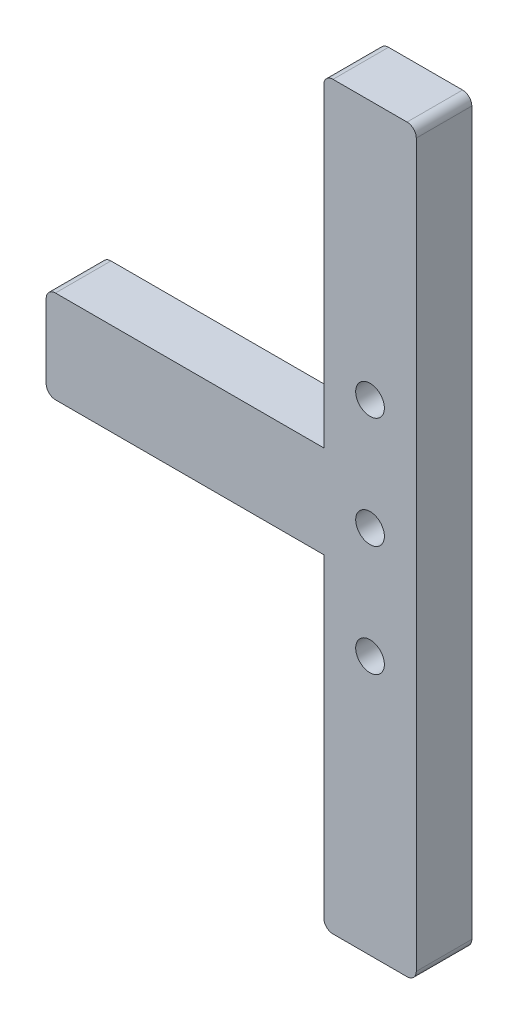
from build123d import *

# Parameters (mm, degrees)
SKETCH_1_W      = 10
SKETCH_1_H      = 80
SKETCH_1_R      = 1.55
SKETCH_1_W_2    = 30
SKETCH_1_H_2    = 10
EXTRUDE_1_DEPTH = 6
FILLET_1_R      = 1


with BuildPart() as part:
    # 草图1 → 凸台-拉伸1 (new body)
    with BuildSketch(Plane.XY):
        Rectangle(SKETCH_1_W, SKETCH_1_H)
        with Locations((0, 12)):
            Circle(SKETCH_1_R, mode=Mode.SUBTRACT)
        Circle(SKETCH_1_R, mode=Mode.SUBTRACT)
        with Locations((0, -12)):
            Circle(SKETCH_1_R, mode=Mode.SUBTRACT)
        with Locations((-20, 0)):
            Rectangle(SKETCH_1_W_2, SKETCH_1_H_2)
    extrude(amount=EXTRUDE_1_DEPTH)

    # 圆角1
    fillet_1_edges = [part.edges().sort_by_distance(p)[0] for p in [
        (-5, 40, 3),
        (5, 40, 3),
        (5, -40, 3),
        (-5, -40, 3),
        (-35, -5, 3),
        (-35, 5, 3),
    ]]
    fillet(fillet_1_edges, radius=FILLET_1_R)


solid = part.part
